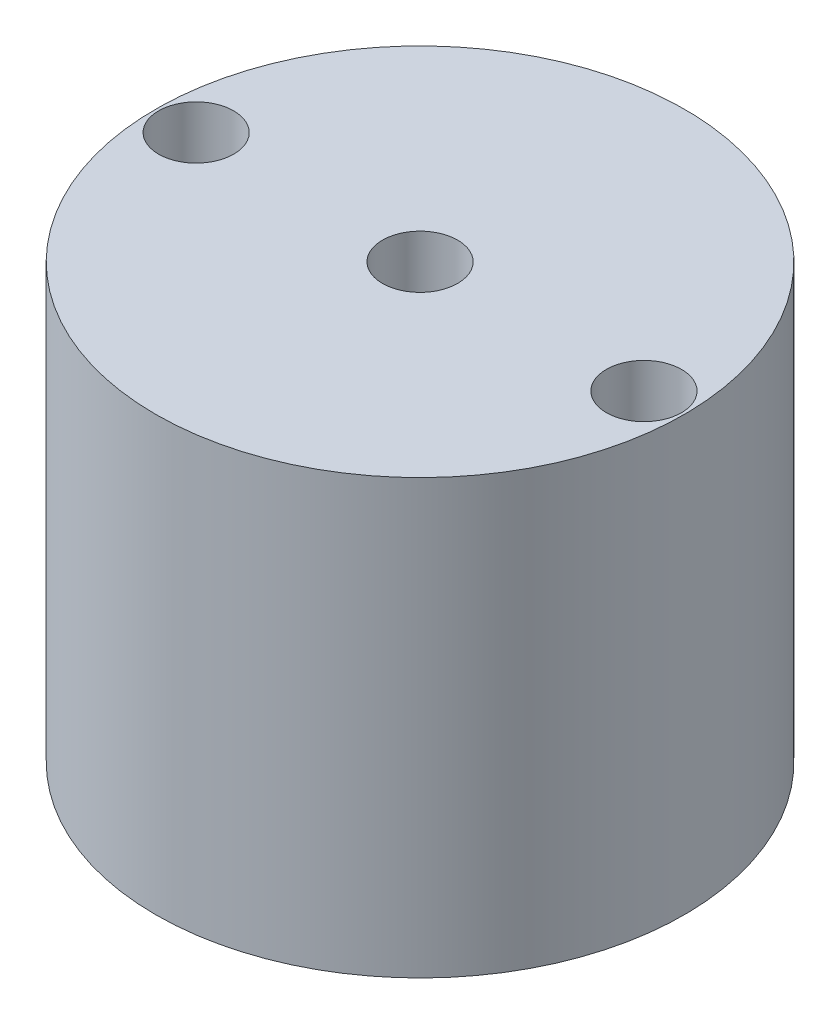
from build123d import *

# Parameters (mm, degrees)
SKETCH1_R           = 23.241
BOSS_EXTRUDE1_DEPTH = 38.1
CUT_EXTRUDE1_REACH  = 40.1
SKETCH2_R           = 3.302
CUT_EXTRUDE2_REACH  = 40.1
SKETCH3_R           = 3.302


with BuildPart() as part:
    # Sketch1 → Boss-Extrude1 (new body)
    with BuildSketch(Plane(origin=(0, 0, 0), x_dir=(1, 0, 0), z_dir=(0, 1, 0))):
        Circle(SKETCH1_R)
    extrude(amount=BOSS_EXTRUDE1_DEPTH)

    # Sketch2 → Cut-Extrude1 (cut, up to next)
    with BuildSketch(Plane(origin=(0, 38.1, 0), x_dir=(1, 0, 0), z_dir=(0, 1, 0)), mode=Mode.PRIVATE) as cut_extrude1_sk1:
        with Locations((19.685, 0)):
            Circle(SKETCH2_R)
    cut_extrude1_tool1 = extrude(cut_extrude1_sk1.sketch, amount=-CUT_EXTRUDE1_REACH, mode=Mode.PRIVATE) & part.part
    add(cut_extrude1_tool1.solids().sort_by_distance((19.685, 38.1, 0))[0], mode=Mode.SUBTRACT)
    # Sketch2 → Cut-Extrude1 (cut, up to next)
    with BuildSketch(Plane(origin=(0, 38.1, 0), x_dir=(1, 0, 0), z_dir=(0, 1, 0)), mode=Mode.PRIVATE) as cut_extrude1_sk2:
        with Locations((-19.685, 0)):
            Circle(SKETCH2_R)
    cut_extrude1_tool2 = extrude(cut_extrude1_sk2.sketch, amount=-CUT_EXTRUDE1_REACH, mode=Mode.PRIVATE) & part.part
    add(cut_extrude1_tool2.solids().sort_by_distance((-19.685, 38.1, 0))[0], mode=Mode.SUBTRACT)

    # Sketch3 → Cut-Extrude2 (cut, up to next)
    with BuildSketch(Plane(origin=(0, 38.1, 0), x_dir=(1, 0, 0), z_dir=(0, 1, 0)), mode=Mode.PRIVATE) as cut_extrude2_sk1:
        Circle(SKETCH3_R)
    cut_extrude2_tool1 = extrude(cut_extrude2_sk1.sketch, amount=-CUT_EXTRUDE2_REACH, mode=Mode.PRIVATE) & part.part
    add(cut_extrude2_tool1.solids().sort_by_distance((0, 38.1, 0))[0], mode=Mode.SUBTRACT)


solid = part.part
